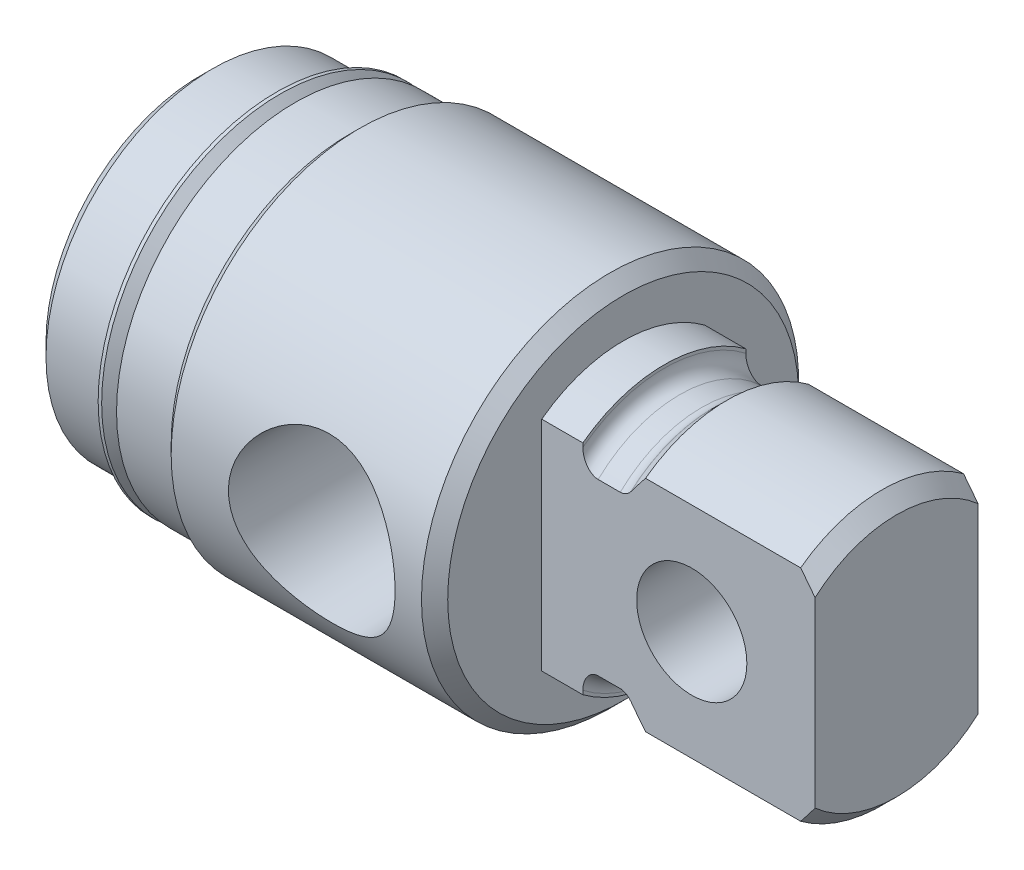
from build123d import *

# Parameters (mm, degrees)
SKETCH3_W               = 43.815
SKETCH3_H               = 87.63
SKETCH3_W_2             = 9.4615
SKETCH3_H_2             = 43.815
CUT_EXTRUDE1_DEPTH      = 15.875
SKETCH7_R               = 3.2004
CUT_EXTRUDE2_DEPTH      = 7.096125
CUT_EXTRUDE2_DEPTH_BACK = 7.096125


with BuildPart() as part:
    # Sketch1 → Revolve1 (revolve)
    with BuildSketch(Plane.XY):
        Polygon((0, 0), (0, 8.90905), (0.762, 9.67105), (4.0386, 9.67105), (4.8006, 8.90905), (5.5626, 8.90905), (5.5626, 10.3759), (8.73633, 10.3759), (9.31418, 10.95375), (23.8506, 10.95375), (24.6126, 10.19175), (24.6126, 0), align=None)
    revolve(axis=Axis((24.6126, 0, 0), (-1, 0, 0)))

    # Sketch2 → Revolve2 (revolve)
    with BuildSketch(Plane.XY):
        with BuildLine():
            Line((24.6126, 0), (24.6126, 7.90575))
            Line((24.6126, 7.90575), (27.0002, 7.90575))
            Line((27.0002, 7.90575), (27.0002, 7.72795))
            ThreePointArc((27.0002, 7.72795), (27.260582072, 7.099332072), (27.8892, 6.83895))
            Line((27.8892, 6.83895), (29.1719, 6.83895))
            ThreePointArc((29.1719, 6.83895), (29.49290348, 6.898927826), (29.77059292, 7.0707683))
            Line((29.77059292, 7.0707683), (29.800517928, 7.09803))
            Line((29.800517928, 7.09803), (30.639987928, 7.9375))
            Line((30.639987928, 7.9375), (39.64813, 7.9375))
            Line((39.64813, 7.9375), (40.4876, 7.09803))
            Line((40.4876, 7.09803), (40.4876, 0))
            Line((40.4876, 0), (24.6126, 0))
        make_face()
    revolve(axis=Axis((40.4876, 0, 0), (-1, 0, 0)))

    # Sketch3 → Cut-Extrude1 (cut)
    with BuildSketch(Plane(origin=(40.4876, 0, 0), x_dir=(0, 0, -1), z_dir=(1, 0, 0))):
        Rectangle(SKETCH3_W, SKETCH3_H)
        Rectangle(SKETCH3_W_2, SKETCH3_H_2, mode=Mode.SUBTRACT)
    extrude(amount=-CUT_EXTRUDE1_DEPTH, mode=Mode.SUBTRACT)

    # Sketch4 → Cut-Revolve1 (revolve, cut)
    with BuildSketch(Plane.XY):
        Polygon((0, 0), (0, 3.9624), (23.58136, 3.9624), (25.869052707, 0), align=None)
    revolve(axis=Axis((25.869052707, 0, 0), (-1, 0, 0)), mode=Mode.SUBTRACT)

    # Sketch5 → Cut-Revolve2 (revolve, cut)
    with BuildSketch(Plane(origin=(0, 0, 0), x_dir=(1, 0, 0), z_dir=(0, 0.999847695, 0.017452406))):
        Polygon((17.4752, 0), (22.075197063, 0), (22.075197063, -3.28295), (22.314675925, -10.95375), (17.4752, -10.95375), align=None)
    revolve(axis=Axis((17.4752, -0.191169297, 10.952081691), (0, 0.017452406, -0.999847695)), mode=Mode.SUBTRACT)

    # Sketch6 → Revolve3 (revolve)
    with BuildSketch(Plane.XY):
        with BuildLine():
            Line((4.49554893, 10.3759), (4.49554893, 10.291731804))
            Line((4.49554893, 10.291731804), (5.440112806, 9.347167928))
            ThreePointArc((5.440112806, 9.347167928), (5.477310245, 9.257365367), (5.440112806, 9.167562806))
            Line((5.440112806, 9.167562806), (5.1816, 8.90905))
            Line((5.1816, 8.90905), (4.8006, 8.90905))
            Line((4.8006, 8.90905), (4.8006, 8.65505))
            Line((4.8006, 8.65505), (5.5626, 8.65505))
            Line((5.5626, 8.65505), (5.5626, 9.51204893))
            Line((5.5626, 9.51204893), (4.69874893, 10.3759))
            Line((4.69874893, 10.3759), (4.49554893, 10.3759))
        make_face()
    revolve(axis=Axis((5.5626, 0, 0), (-1, 0, 0)))

    # Sketch7 → Cut-Extrude2 (cut, two sides)
    with BuildSketch(Plane.XY) as cut_extrude2_sk:
        with Locations((33.3248, 0)):
            Circle(SKETCH7_R)
    extrude(amount=CUT_EXTRUDE2_DEPTH, mode=Mode.SUBTRACT)
    extrude(cut_extrude2_sk.sketch, amount=-CUT_EXTRUDE2_DEPTH_BACK, mode=Mode.SUBTRACT)


solid = part.part
